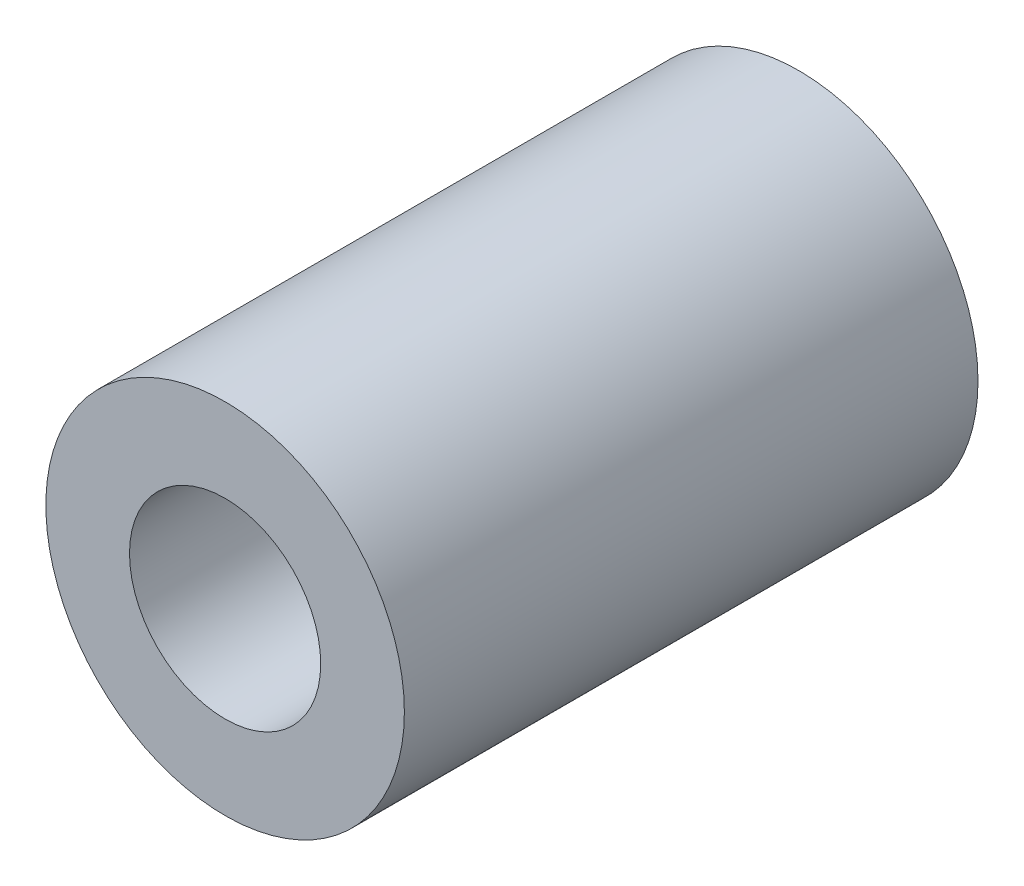
from build123d import *

# Parameters (mm, degrees)
SKETCH1_R           = 7.5
BOSS_EXTRUDE1_DEPTH = 24
SKETCH2_R           = 4
CUT_EXTRUDE1_DEPTH  = 24


with BuildPart() as part:
    # Sketch1 → Boss-Extrude1 (new body)
    with BuildSketch(Plane.XY):
        Circle(SKETCH1_R)
    extrude(amount=BOSS_EXTRUDE1_DEPTH)

    # Sketch2 → Cut-Extrude1 (cut)
    with BuildSketch(Plane.XY.offset(24)):
        Circle(SKETCH2_R)
    extrude(amount=-CUT_EXTRUDE1_DEPTH, mode=Mode.SUBTRACT)


solid = part.part
